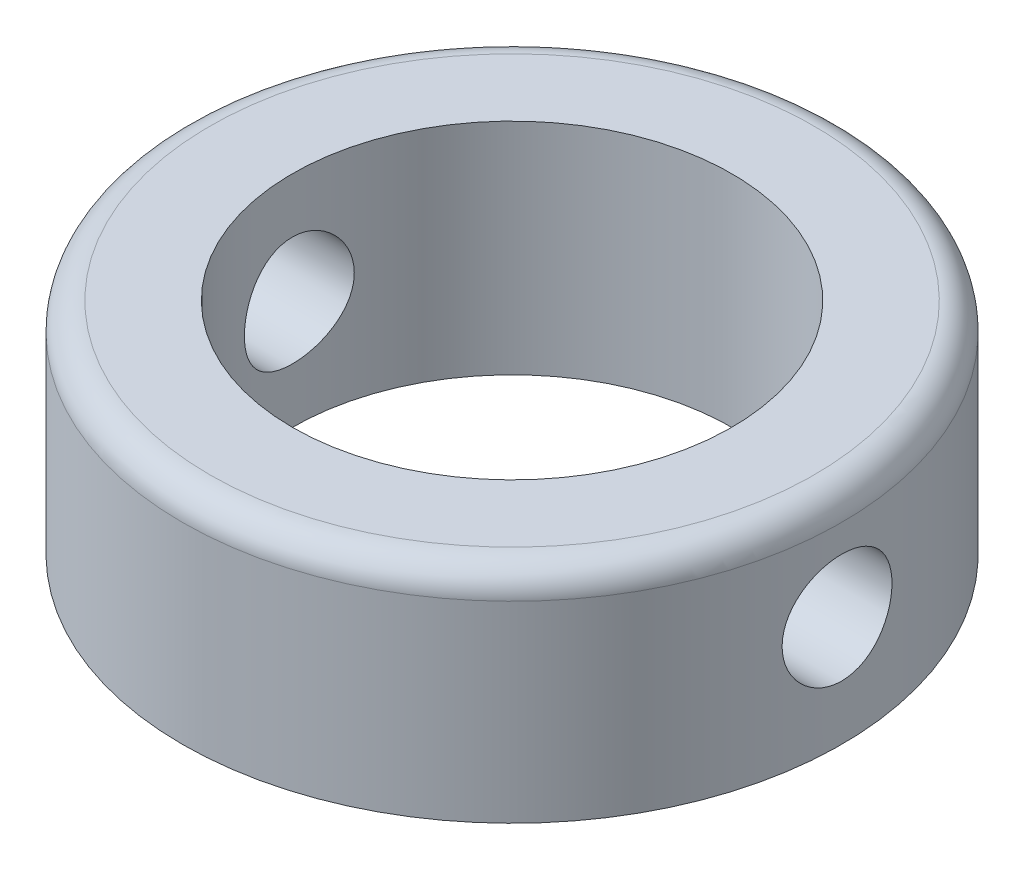
from build123d import *

# Parameters (mm, degrees)
SKETCH1_R           = 12
SKETCH1_R_2         = 8
BOSS_EXTRUDE1_DEPTH = 8
FILLET1_R           = 1
SKETCH2_R           = 2
CUT_EXTRUDE1_DEPTH  = 24


with BuildPart() as part:
    # Sketch1 → Boss-Extrude1 (new body)
    with BuildSketch(Plane(origin=(0, 0, 0), x_dir=(1, 0, 0), z_dir=(0, 1, 0))):
        Circle(SKETCH1_R)
        Circle(SKETCH1_R_2, mode=Mode.SUBTRACT)
    extrude(amount=BOSS_EXTRUDE1_DEPTH)

    # Fillet1
    fillet1_edges = [part.edges().sort_by_distance(p)[0] for p in [
        (-12, 8, 0),
    ]]
    fillet(fillet1_edges, radius=FILLET1_R)

    # Sketch2 → Cut-Extrude1 (cut, symmetric)
    with BuildSketch(Plane(origin=(0, 0, 0), x_dir=(0, 0, -1), z_dir=(1, 0, 0))):
        with Locations((0, 4)):
            Circle(SKETCH2_R)
    extrude(amount=CUT_EXTRUDE1_DEPTH, both=True, mode=Mode.SUBTRACT)


solid = part.part
